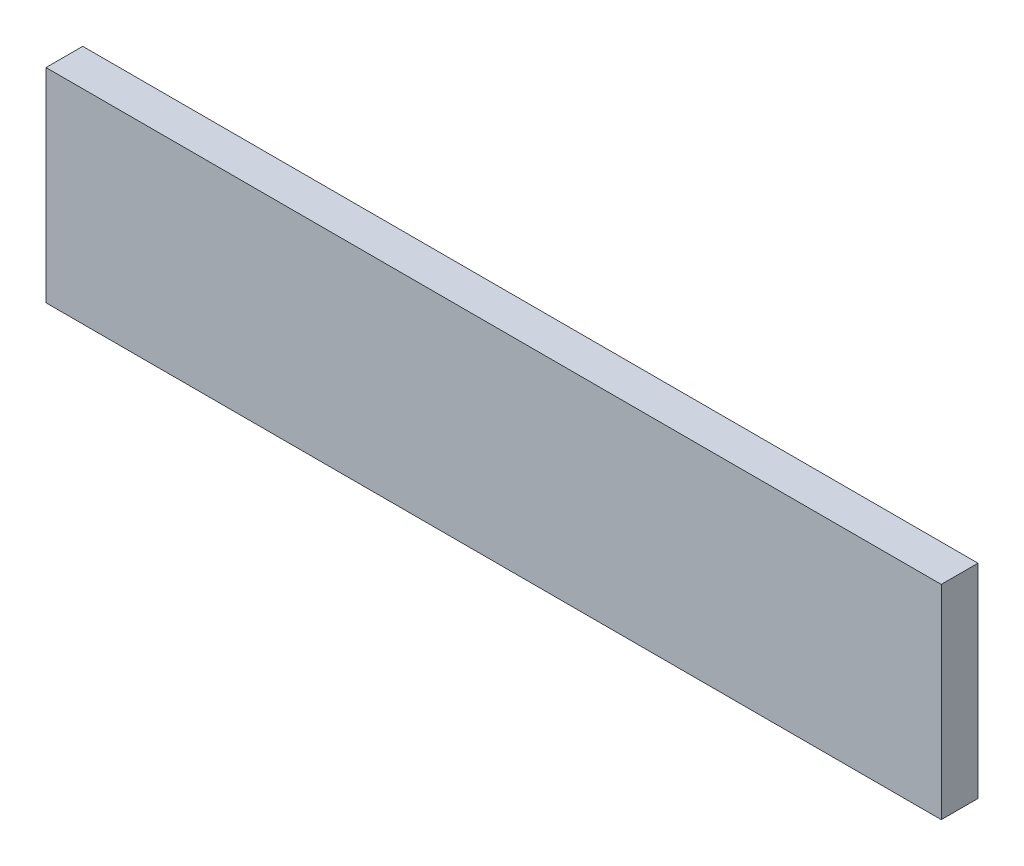
from build123d import *

# Parameters (mm, degrees)
SKETCH1_W           = 536
SKETCH1_H           = 150
BOSS_EXTRUDE1_DEPTH = 22
SKETCH2_W           = 536
SKETCH2_H           = 28
CUT_EXTRUDE1_DEPTH  = 23


with BuildPart() as part:
    # Sketch1 → Boss-Extrude1 (new body)
    with BuildSketch(Plane.XY):
        Rectangle(SKETCH1_W, SKETCH1_H)
    extrude(amount=BOSS_EXTRUDE1_DEPTH)

    # Sketch2 → Cut-Extrude1 (cut, through all)
    with BuildSketch(Plane.XY.offset(22)):
        with Locations((0, 61)):
            Rectangle(SKETCH2_W, SKETCH2_H)
    extrude(amount=-CUT_EXTRUDE1_DEPTH, mode=Mode.SUBTRACT)


solid = part.part
